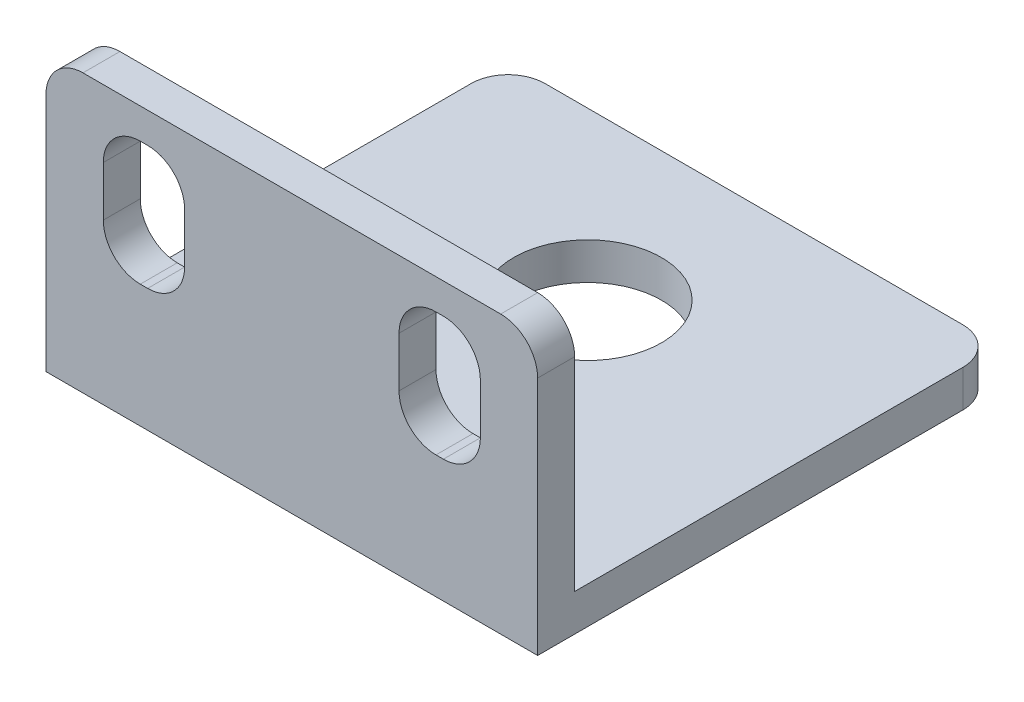
from build123d import *

# Parameters (mm, degrees)
SKETCH1_W           = 26.6
SKETCH1_H           = 25
BOSS_EXTRUDE1_DEPTH = 2
SKETCH2_W           = 26.6
SKETCH2_H           = 2
BOSS_EXTRUDE2_DEPTH = 13
SKETCH3_W           = 4.4
SKETCH3_H           = 6.7
CUT_EXTRUDE1_DEPTH  = 3
FILLET1_R           = 2
SKETCH4_R           = 4
CUT_EXTRUDE2_DEPTH  = 3


with BuildPart() as part:
    # Sketch1 → Boss-Extrude1 (new body)
    with BuildSketch(Plane(origin=(0, 0, 0), x_dir=(1, 0, 0), z_dir=(0, 1, 0))):
        Rectangle(SKETCH1_W, SKETCH1_H)
    extrude(amount=BOSS_EXTRUDE1_DEPTH)

    # Sketch2 → Boss-Extrude2 (add)
    with BuildSketch(Plane(origin=(0, 2, 0), x_dir=(1, 0, 0), z_dir=(0, 1, 0))):
        with Locations((0, -11.5)):
            Rectangle(SKETCH2_W, SKETCH2_H)
    extrude(amount=BOSS_EXTRUDE2_DEPTH)

    # Sketch3 → Cut-Extrude1 (cut, through all)
    with BuildSketch(Plane(origin=(0, 0, 10.5), x_dir=(-1, 0, 0), z_dir=(0, 0, -1))):
        with Locations((-8, 10)):
            Rectangle(SKETCH3_W, SKETCH3_H)
        with Locations((8, 10)):
            Rectangle(SKETCH3_W, SKETCH3_H)
    extrude(amount=-CUT_EXTRUDE1_DEPTH, mode=Mode.SUBTRACT)

    # Fillet1
    fillet1_edges = [part.edges().sort_by_distance(p)[0] for p in [
        (-13.3, 1, -12.5),
        (13.3, 1, -12.5),
        (5.8, 6.65, 11.5),
        (10.2, 6.65, 11.5),
        (-10.2, 6.65, 11.5),
        (-5.8, 6.65, 11.5),
        (-10.2, 13.35, 11.5),
        (-5.8, 13.35, 11.5),
        (5.8, 13.35, 11.5),
        (10.2, 13.35, 11.5),
        (13.3, 15, 11.5),
        (-13.3, 15, 11.5),
    ]]
    fillet(fillet1_edges, radius=FILLET1_R)

    # Sketch4 → Cut-Extrude2 (cut, through all)
    with BuildSketch(Plane(origin=(0, 2, 0), x_dir=(1, 0, 0), z_dir=(0, 1, 0))):
        with Locations((0, 3.5)):
            Circle(SKETCH4_R)
    extrude(amount=-CUT_EXTRUDE2_DEPTH, mode=Mode.SUBTRACT)


solid = part.part
